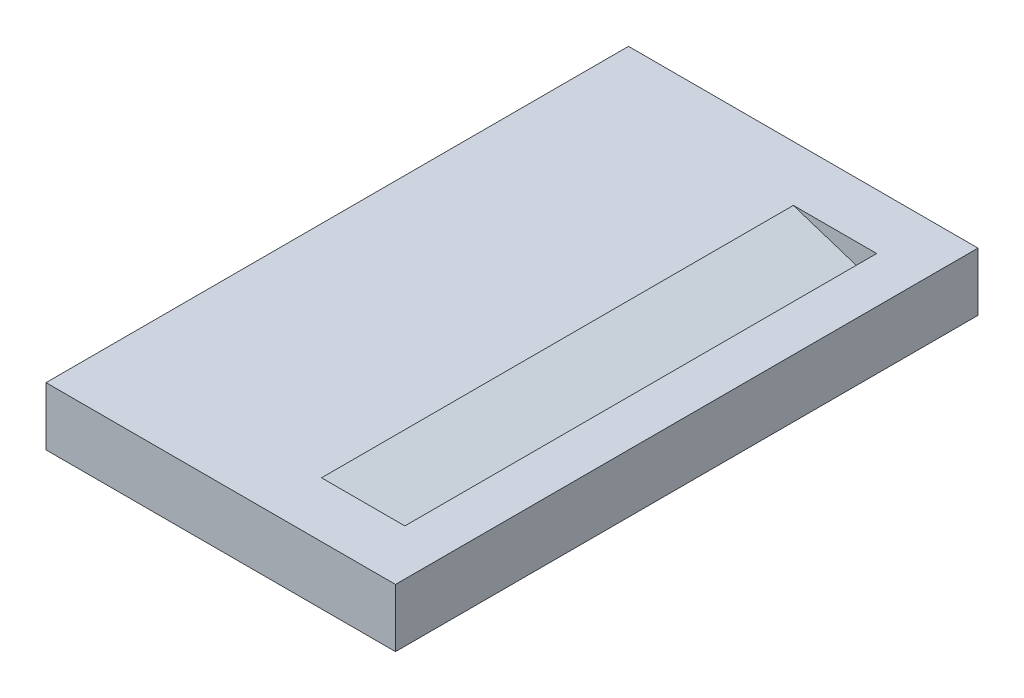
from build123d import *

# Parameters (mm, degrees)
SKETCH_1_W          = 89.55
SKETCH_1_H          = 50
EXTRUDE_1_DEPTH     = 5
CUT_EXTRUDE_1_DEPTH = 4
SKETCH_6_W          = 40.5
SKETCH_6_H          = 93
CUT_EXTRUDE_2_DEPTH = 3.43
SKETCH_7_W          = 59.55
SKETCH_7_H          = 5
CUT_EXTRUDE_3_DEPTH = 51


with BuildPart() as part:
    # 草圖1 → 填料-伸長1 (new body)
    with BuildSketch(Plane(origin=(0, 0, 0), x_dir=(1, 0, 0), z_dir=(0, 1, 0))):
        Rectangle(SKETCH_1_W, SKETCH_1_H)
    extrude(amount=EXTRUDE_1_DEPTH)

    # 草圖2 → 除料-伸長1 (cut)
    with BuildSketch(Plane(origin=(0, 5, 0), x_dir=(1, 0, 0), z_dir=(0, 1, 0))):
        Polygon((-39.775, 5.2), (-7.375, 5.2), (-7.375, -5.2), (-39.775, -5.2), (-39.775, -4), (-44.775, -4), (-44.775, 4), (-39.775, 4), align=None)
    extrude(amount=-CUT_EXTRUDE_1_DEPTH, mode=Mode.SUBTRACT)

    # 草圖6 → 除料-伸長2 (cut)
    with BuildSketch(Plane(origin=(5.745095169, 17.681584822, 0), x_dir=(0, 0, -1), z_dir=(0.309016994, 0.951056516, 0))):
        with Locations((0, 9.21448352)):
            Rectangle(SKETCH_6_W, SKETCH_6_H)
    extrude(amount=-CUT_EXTRUDE_2_DEPTH, mode=Mode.SUBTRACT)

    # 草圖7 → 除料-伸長3 (cut, through all)
    with BuildSketch(Plane.XY.offset(25)):
        with Locations((-15, 2.5)):
            Rectangle(SKETCH_7_W, SKETCH_7_H)
    extrude(amount=-CUT_EXTRUDE_3_DEPTH, mode=Mode.SUBTRACT)


solid = part.part
